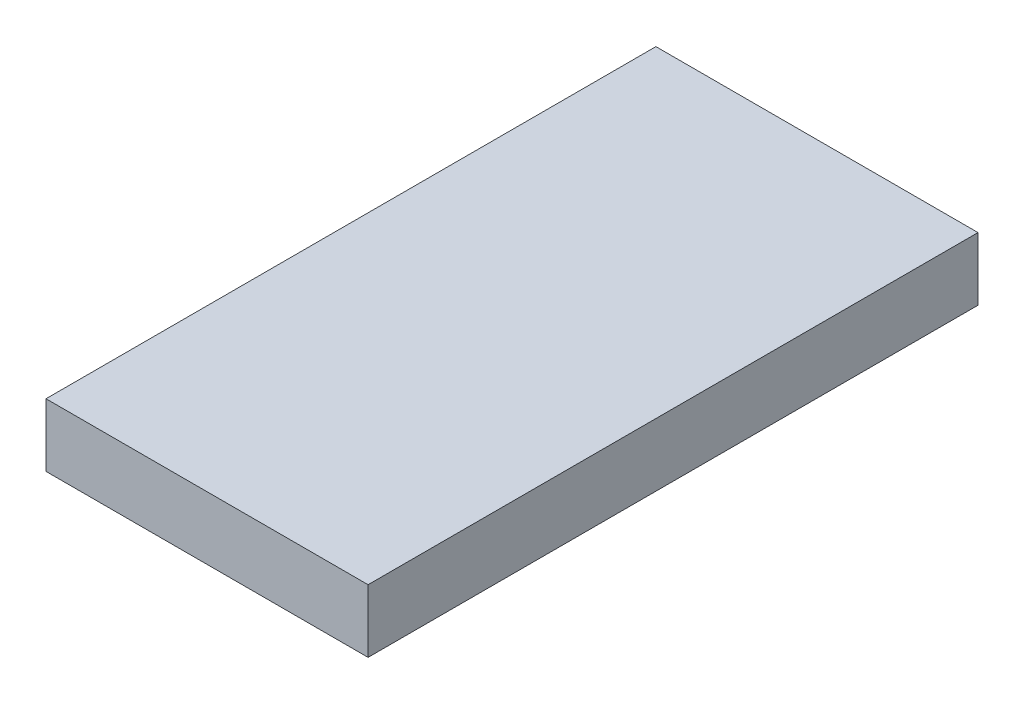
from build123d import *

# Parameters (mm, degrees)
SKETCH1_W           = 35.814
SKETCH1_H           = 67.818
BOSS_EXTRUDE1_DEPTH = 7


with BuildPart() as part:
    # Sketch1 → Boss-Extrude1 (new body)
    with BuildSketch(Plane(origin=(0, 0, 0), x_dir=(1, 0, 0), z_dir=(0, 1, 0))):
        Rectangle(SKETCH1_W, SKETCH1_H)
    extrude(amount=BOSS_EXTRUDE1_DEPTH)


solid = part.part
